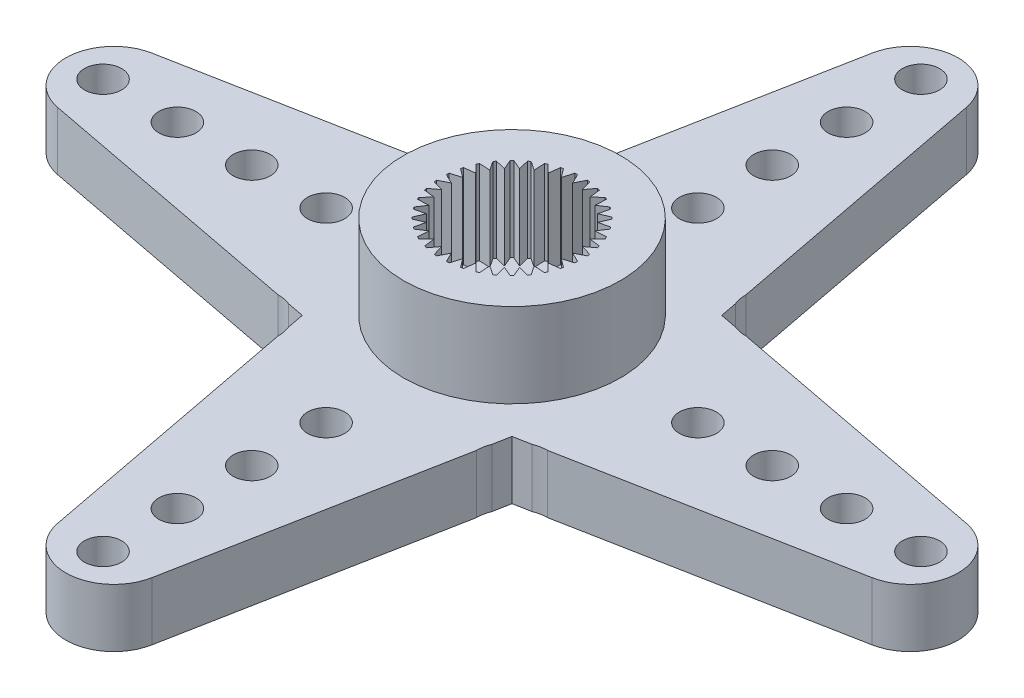
from build123d import *

# Parameters (mm, degrees)
BOSS_EXTRUDE1_DEPTH                                = 2.35
CUT_EXTRUDE1_DEPTH                                 = 2.35
CUT_EXTRUDE2_DEPTH                                 = 2.35
CUT_EXTRUDE3_DEPTH                                 = 2.35
CUT_EXTRUDE4_DEPTH                                 = 2.35
CUT_EXTRUDE5_DEPTH                                 = 2.35
CUT_EXTRUDE6_DEPTH                                 = 2.35
CUT_EXTRUDE7_DEPTH                                 = 2.35
CUT_EXTRUDE8_DEPTH                                 = 2.35
SKETCH10_R                                         = 4.375
BOSS_EXTRUDE2_DEPTH                                = 3.4
CUT_EXTRUDE9_DEPTH                                 = 3.4
F_8_8_8_8_DIAMETER_HOLE1_D                         = 8.8
F_8_8_8_8_DIAMETER_HOLE1_DEPTH                     = 0.3
SKETCH14_W                                         = 3.25
SKETCH14_H                                         = 0.3
F_1_5_1_5_DIAMETER_HOLE1_D                         = 1.5
F_1_5_1_5_DIAMETER_HOLE1_DEPTH                     = 2.35
CBORE_FOR_M2_5_HEX_HEAD_MACHINE_SCREW1_D           = 3
CBORE_FOR_M2_5_HEX_HEAD_MACHINE_SCREW1_DEPTH       = 5.75
CBORE_FOR_M2_5_HEX_HEAD_MACHINE_SCREW1_CBORE_D     = 5.5
CBORE_FOR_M2_5_HEX_HEAD_MACHINE_SCREW1_CBORE_DEPTH = 0.3


with BuildPart() as part:
    # Sketch1 → Boss-Extrude1 (new body)
    with BuildSketch(Plane(origin=(0, 2.35, 0), x_dir=(1, 0, 0), z_dir=(0, 1, 0))):
        with BuildLine():
            Line((-16.428641042, -1.9), (-4.230530925, -4.230530925))
            Line((-4.230530925, -4.230530925), (-1.9, -16.428641042))
            ThreePointArc((-1.9, -16.428641042), (0, -18), (1.9, -16.428641042))
            Line((1.9, -16.428641042), (4.230530925, -4.230530925))
            Line((4.230530925, -4.230530925), (16.428641042, -1.9))
            ThreePointArc((16.428641042, -1.9), (18, 0), (16.428641042, 1.9))
            Line((16.428641042, 1.9), (4.230530925, 4.230530925))
            Line((4.230530925, 4.230530925), (1.9, 16.428641042))
            ThreePointArc((1.9, 16.428641042), (0, 18), (-1.9, 16.428641042))
            Line((-1.9, 16.428641042), (-4.230530925, 4.230530925))
            Line((-4.230530925, 4.230530925), (-16.428641042, 1.9))
            ThreePointArc((-16.428641042, 1.9), (-18, 0), (-16.428641042, -1.9))
        make_face()
    extrude(amount=-BOSS_EXTRUDE1_DEPTH)

    # Sketch2 → Cut-Extrude1 (cut)
    with BuildSketch(Plane.XZ):
        with BuildLine():
            Line((4.101224008, 4.907329504), (4, 5.437140793))
            ThreePointArc((4, 5.437140793), (4.025532815, 5.167443601), (4.101224008, 4.907329504))
        make_face()
    extrude(amount=-CUT_EXTRUDE1_DEPTH, mode=Mode.SUBTRACT)

    # Sketch3 → Cut-Extrude2 (cut)
    with BuildSketch(Plane.XZ):
        with BuildLine():
            Line((5.437140793, 4), (4.907329504, 4.101224008))
            ThreePointArc((4.907329504, 4.101224008), (5.167443601, 4.025532815), (5.437140793, 4))
        make_face()
    extrude(amount=-CUT_EXTRUDE2_DEPTH, mode=Mode.SUBTRACT)

    # Sketch4 → Cut-Extrude3 (cut)
    with BuildSketch(Plane.XZ):
        with BuildLine():
            Line((4.907329504, -4.101224008), (5.437140793, -4))
            ThreePointArc((5.437140793, -4), (5.167443601, -4.025532815), (4.907329504, -4.101224008))
        make_face()
    extrude(amount=-CUT_EXTRUDE3_DEPTH, mode=Mode.SUBTRACT)

    # Sketch5 → Cut-Extrude4 (cut)
    with BuildSketch(Plane.XZ):
        with BuildLine():
            Line((4, -5.437140793), (4.101224008, -4.907329504))
            ThreePointArc((4.101224008, -4.907329504), (4.025532815, -5.167443601), (4, -5.437140793))
        make_face()
    extrude(amount=-CUT_EXTRUDE4_DEPTH, mode=Mode.SUBTRACT)

    # Sketch6 → Cut-Extrude5 (cut)
    with BuildSketch(Plane.XZ):
        with BuildLine():
            Line((-4.101224008, -4.907329504), (-4, -5.437140793))
            ThreePointArc((-4, -5.437140793), (-4.025532815, -5.167443601), (-4.101224008, -4.907329504))
        make_face()
    extrude(amount=-CUT_EXTRUDE5_DEPTH, mode=Mode.SUBTRACT)

    # Sketch7 → Cut-Extrude6 (cut)
    with BuildSketch(Plane.XZ):
        with BuildLine():
            Line((-5.437140793, -4), (-4.907329504, -4.101224008))
            ThreePointArc((-4.907329504, -4.101224008), (-5.167443601, -4.025532815), (-5.437140793, -4))
        make_face()
    extrude(amount=-CUT_EXTRUDE6_DEPTH, mode=Mode.SUBTRACT)

    # Sketch8 → Cut-Extrude7 (cut)
    with BuildSketch(Plane.XZ):
        with BuildLine():
            Line((-4.907329504, 4.101224008), (-5.437140793, 4))
            ThreePointArc((-5.437140793, 4), (-5.167443601, 4.025532815), (-4.907329504, 4.101224008))
        make_face()
    extrude(amount=-CUT_EXTRUDE7_DEPTH, mode=Mode.SUBTRACT)

    # Sketch9 → Cut-Extrude8 (cut)
    with BuildSketch(Plane.XZ):
        with BuildLine():
            Line((-4, 5.437140793), (-4.101224008, 4.907329504))
            ThreePointArc((-4.101224008, 4.907329504), (-4.025532815, 5.167443601), (-4, 5.437140793))
        make_face()
    extrude(amount=-CUT_EXTRUDE8_DEPTH, mode=Mode.SUBTRACT)

    # Sketch10 → Boss-Extrude2 (add)
    with BuildSketch(Plane(origin=(0, 2.35, 0), x_dir=(-1, 0, 0), z_dir=(0, 1, 0))):
        Circle(SKETCH10_R)
    extrude(amount=BOSS_EXTRUDE2_DEPTH)

    # Sketch11 → Cut-Extrude9 (cut)
    with BuildSketch(Plane(origin=(0, 5.75, 0), x_dir=(-1, 0, 0), z_dir=(0, 1, 0))):
        with BuildLine():
            Line((0.687336745, 2.765875666), (0.425438035, 2.412778995))
            Line((0.425438035, 2.412778995), (0.300099924, 2.834155965))
            ThreePointArc((0.300099924, 2.834155965), (0.248393867, 2.83915489), (0.196605286, 2.843210573))
            Line((0.196605286, 2.843210573), (0, 2.45))
            Line((0, 2.45), (-0.196605286, 2.843210573))
            ThreePointArc((-0.196605286, 2.843210573), (-0.248393867, 2.83915489), (-0.300099924, 2.834155965))
            Line((-0.300099924, 2.834155965), (-0.425438035, 2.412778995))
            Line((-0.425438035, 2.412778995), (-0.687336745, 2.765875666))
            ThreePointArc((-0.687336745, 2.765875666), (-0.737634279, 2.752888605), (-0.787686751, 2.738986963))
            Line((-0.787686751, 2.738986963), (-0.837949351, 2.302246921))
            Line((-0.837949351, 2.302246921), (-1.157183824, 2.604501026))
            ThreePointArc((-1.157183824, 2.604501026), (-1.204462046, 2.582977193), (-1.251340114, 2.560595228))
            Line((-1.251340114, 2.560595228), (-1.225, 2.121762239))
            Line((-1.225, 2.121762239), (-1.591870459, 2.363989941))
            ThreePointArc((-1.591870459, 2.363989941), (-1.634692844, 2.334583326), (-1.676972141, 2.304401102))
            Line((-1.676972141, 2.304401102), (-1.574829644, 1.876808886))
            Line((-1.574829644, 1.876808886), (-1.978188915, 2.051650218))
            ThreePointArc((-1.978188915, 2.051650218), (-2.015254326, 2.015254326), (-2.051650218, 1.978188915))
            Line((-2.051650218, 1.978188915), (-1.876808886, 1.574829644))
            Line((-1.876808886, 1.574829644), (-2.304401102, 1.676972141))
            ThreePointArc((-2.304401102, 1.676972141), (-2.334583326, 1.634692844), (-2.363989941, 1.591870459))
            Line((-2.363989941, 1.591870459), (-2.121762239, 1.225))
            Line((-2.121762239, 1.225), (-2.560595228, 1.251340114))
            ThreePointArc((-2.560595228, 1.251340114), (-2.582977193, 1.204462046), (-2.604501026, 1.157183824))
            Line((-2.604501026, 1.157183824), (-2.302246921, 0.837949351))
            Line((-2.302246921, 0.837949351), (-2.738986963, 0.787686751))
            ThreePointArc((-2.738986963, 0.787686751), (-2.752888605, 0.737634279), (-2.765875666, 0.687336745))
            Line((-2.765875666, 0.687336745), (-2.412778995, 0.425438035))
            Line((-2.412778995, 0.425438035), (-2.834155965, 0.300099924))
            ThreePointArc((-2.834155965, 0.300099924), (-2.83915489, 0.248393867), (-2.843210573, 0.196605286))
            Line((-2.843210573, 0.196605286), (-2.45, 0))
            Line((-2.45, 0), (-2.843210573, -0.196605286))
            ThreePointArc((-2.843210573, -0.196605286), (-2.83915489, -0.248393867), (-2.834155965, -0.300099924))
            Line((-2.834155965, -0.300099924), (-2.412778995, -0.425438035))
            Line((-2.412778995, -0.425438035), (-2.765875666, -0.687336745))
            ThreePointArc((-2.765875666, -0.687336745), (-2.752888605, -0.737634279), (-2.738986963, -0.787686751))
            Line((-2.738986963, -0.787686751), (-2.302246921, -0.837949351))
            Line((-2.302246921, -0.837949351), (-2.604501026, -1.157183824))
            ThreePointArc((-2.604501026, -1.157183824), (-2.582977193, -1.204462046), (-2.560595228, -1.251340114))
            Line((-2.560595228, -1.251340114), (-2.121762239, -1.225))
            Line((-2.121762239, -1.225), (-2.363989941, -1.591870459))
            ThreePointArc((-2.363989941, -1.591870459), (-2.334583326, -1.634692844), (-2.304401102, -1.676972141))
            Line((-2.304401102, -1.676972141), (-1.876808886, -1.574829644))
            Line((-1.876808886, -1.574829644), (-2.051650218, -1.978188915))
            ThreePointArc((-2.051650218, -1.978188915), (-2.015254326, -2.015254326), (-1.978188915, -2.051650218))
            Line((-1.978188915, -2.051650218), (-1.574829644, -1.876808886))
            Line((-1.574829644, -1.876808886), (-1.676972141, -2.304401102))
            ThreePointArc((-1.676972141, -2.304401102), (-1.634692844, -2.334583326), (-1.591870459, -2.363989941))
            Line((-1.591870459, -2.363989941), (-1.225, -2.121762239))
            Line((-1.225, -2.121762239), (-1.251340114, -2.560595228))
            ThreePointArc((-1.251340114, -2.560595228), (-1.204462046, -2.582977193), (-1.157183824, -2.604501026))
            Line((-1.157183824, -2.604501026), (-0.837949351, -2.302246921))
            Line((-0.837949351, -2.302246921), (-0.787686751, -2.738986963))
            ThreePointArc((-0.787686751, -2.738986963), (-0.737634279, -2.752888605), (-0.687336745, -2.765875666))
            Line((-0.687336745, -2.765875666), (-0.425438035, -2.412778995))
            Line((-0.425438035, -2.412778995), (-0.300099924, -2.834155965))
            ThreePointArc((-0.300099924, -2.834155965), (-0.248393867, -2.83915489), (-0.196605286, -2.843210573))
            Line((-0.196605286, -2.843210573), (0, -2.45))
            Line((0, -2.45), (0.196605286, -2.843210573))
            ThreePointArc((0.196605286, -2.843210573), (0.248393867, -2.83915489), (0.300099924, -2.834155965))
            Line((0.300099924, -2.834155965), (0.425438035, -2.412778995))
            Line((0.425438035, -2.412778995), (0.687336745, -2.765875666))
            ThreePointArc((0.687336745, -2.765875666), (0.737634279, -2.752888605), (0.787686751, -2.738986963))
            Line((0.787686751, -2.738986963), (0.837949351, -2.302246921))
            Line((0.837949351, -2.302246921), (1.157183824, -2.604501026))
            ThreePointArc((1.157183824, -2.604501026), (1.204462046, -2.582977193), (1.251340114, -2.560595228))
            Line((1.251340114, -2.560595228), (1.225, -2.121762239))
            Line((1.225, -2.121762239), (1.591870459, -2.363989941))
            ThreePointArc((1.591870459, -2.363989941), (1.634692844, -2.334583326), (1.676972141, -2.304401102))
            Line((1.676972141, -2.304401102), (1.574829644, -1.876808886))
            Line((1.574829644, -1.876808886), (1.978188915, -2.051650218))
            ThreePointArc((1.978188915, -2.051650218), (2.015254326, -2.015254326), (2.051650218, -1.978188915))
            Line((2.051650218, -1.978188915), (1.876808886, -1.574829644))
            Line((1.876808886, -1.574829644), (2.304401102, -1.676972141))
            ThreePointArc((2.304401102, -1.676972141), (2.334583326, -1.634692844), (2.363989941, -1.591870459))
            Line((2.363989941, -1.591870459), (2.121762239, -1.225))
            Line((2.121762239, -1.225), (2.560595228, -1.251340114))
            ThreePointArc((2.560595228, -1.251340114), (2.582977193, -1.204462046), (2.604501026, -1.157183824))
            Line((2.604501026, -1.157183824), (2.302246921, -0.837949351))
            Line((2.302246921, -0.837949351), (2.738986963, -0.787686751))
            ThreePointArc((2.738986963, -0.787686751), (2.752888605, -0.737634279), (2.765875666, -0.687336745))
            Line((2.765875666, -0.687336745), (2.412778995, -0.425438035))
            Line((2.412778995, -0.425438035), (2.834155965, -0.300099924))
            ThreePointArc((2.834155965, -0.300099924), (2.83915489, -0.248393867), (2.843210573, -0.196605286))
            Line((2.843210573, -0.196605286), (2.45, 0))
            Line((2.45, 0), (2.843210573, 0.196605286))
            ThreePointArc((2.843210573, 0.196605286), (2.83915489, 0.248393867), (2.834155965, 0.300099924))
            Line((2.834155965, 0.300099924), (2.412778995, 0.425438035))
            Line((2.412778995, 0.425438035), (2.765875666, 0.687336745))
            ThreePointArc((2.765875666, 0.687336745), (2.752888605, 0.737634279), (2.738986963, 0.787686751))
            Line((2.738986963, 0.787686751), (2.302246921, 0.837949351))
            Line((2.302246921, 0.837949351), (2.604501026, 1.157183824))
            ThreePointArc((2.604501026, 1.157183824), (2.582977193, 1.204462046), (2.560595228, 1.251340114))
            Line((2.560595228, 1.251340114), (2.121762239, 1.225))
            Line((2.121762239, 1.225), (2.363989941, 1.591870459))
            ThreePointArc((2.363989941, 1.591870459), (2.334583326, 1.634692844), (2.304401102, 1.676972141))
            Line((2.304401102, 1.676972141), (1.876808886, 1.574829644))
            Line((1.876808886, 1.574829644), (2.051650218, 1.978188915))
            ThreePointArc((2.051650218, 1.978188915), (2.015254326, 2.015254326), (1.978188915, 2.051650218))
            Line((1.978188915, 2.051650218), (1.574829644, 1.876808886))
            Line((1.574829644, 1.876808886), (1.676972141, 2.304401102))
            ThreePointArc((1.676972141, 2.304401102), (1.634692844, 2.334583326), (1.591870459, 2.363989941))
            Line((1.591870459, 2.363989941), (1.225, 2.121762239))
            Line((1.225, 2.121762239), (1.251340114, 2.560595228))
            ThreePointArc((1.251340114, 2.560595228), (1.204462046, 2.582977193), (1.157183824, 2.604501026))
            Line((1.157183824, 2.604501026), (0.837949351, 2.302246921))
            Line((0.837949351, 2.302246921), (0.787686751, 2.738986963))
            ThreePointArc((0.787686751, 2.738986963), (0.737634279, 2.752888605), (0.687336745, 2.765875666))
        make_face()
    extrude(amount=-CUT_EXTRUDE9_DEPTH, mode=Mode.SUBTRACT)

    # Ø8.8 (8.8) Diameter Hole1
    with Locations(Plane(origin=(0, 0, 0), x_dir=(-1, 0, 0), z_dir=(0, -1, 0))):
        with Locations((0, 0)):
            Hole(F_8_8_8_8_DIAMETER_HOLE1_D / 2, depth=F_8_8_8_8_DIAMETER_HOLE1_DEPTH)

    # Sketch14 → Revolve1 (revolve)
    with BuildSketch(Plane.XY):
        with Locations((1.625, 0.15)):
            Rectangle(SKETCH14_W, SKETCH14_H)
    revolve(axis=Axis((0, 0.3, 0), (0, -1, 0)))

    # Ø1.5 (1.5) Diameter Hole1
    with Locations(Plane(origin=(0, 2.35, 0), x_dir=(1, 0, 0), z_dir=(0, 1, 0))):
        with Locations((0, -7.5), (0, -10.5), (0, -13.5), (0, -16.5), (7.5, 0), (10.5, 0), (13.5, 0), (16.5, 0), (0, 7.5), (0, 10.5), (0, 13.5), (0, 16.5), (-7.5, 0), (-10.5, 0), (-13.5, 0), (-16.5, 0)):
            Hole(F_1_5_1_5_DIAMETER_HOLE1_D / 2, depth=F_1_5_1_5_DIAMETER_HOLE1_DEPTH)

    # CBORE for M2.5 Hex Head Machine Screw1
    with Locations(Plane(origin=(0, 0, 0), x_dir=(-1, 0, 0), z_dir=(0, -1, 0))):
        with Locations((0, 0)):
            CounterBoreHole(CBORE_FOR_M2_5_HEX_HEAD_MACHINE_SCREW1_D / 2, CBORE_FOR_M2_5_HEX_HEAD_MACHINE_SCREW1_CBORE_D / 2, CBORE_FOR_M2_5_HEX_HEAD_MACHINE_SCREW1_CBORE_DEPTH, depth=CBORE_FOR_M2_5_HEX_HEAD_MACHINE_SCREW1_DEPTH)


solid = part.part
